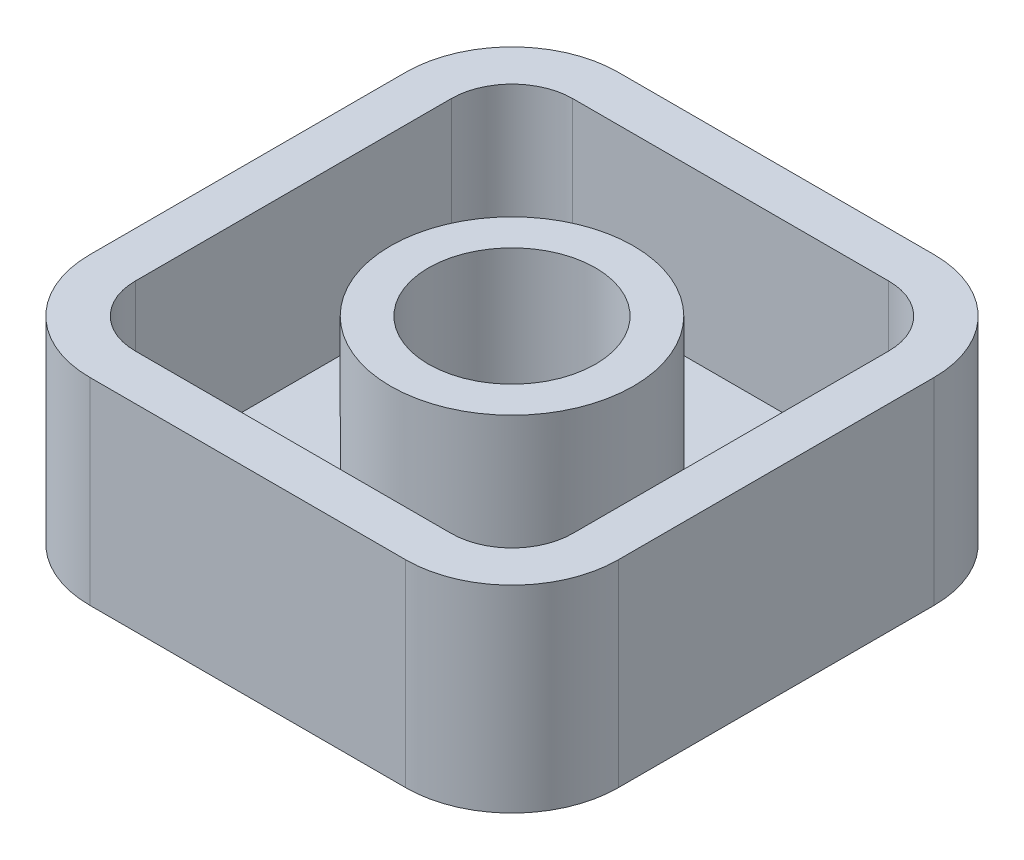
from build123d import *

# Parameters (mm, degrees)
SKETCH1_W           = 17.4
SKETCH1_H           = 17.4
BOSS_EXTRUDE1_DEPTH = 6.5
FILLET1_R           = 3.5
CUT_EXTRUDE1_DEPTH  = 5.5
SKETCH3_R           = 4
SKETCH3_R_2         = 2.75
BOSS_EXTRUDE2_DEPTH = 5.5
SKETCH4_R           = 2.75
CUT_EXTRUDE2_DEPTH  = 0.4


with BuildPart() as part:
    # Sketch1 → Boss-Extrude1 (new body)
    with BuildSketch(Plane(origin=(0, 0, 0), x_dir=(1, 0, 0), z_dir=(0, 1, 0))):
        with Locations((-8.7, -8.7)):
            Rectangle(SKETCH1_W, SKETCH1_H)
    extrude(amount=BOSS_EXTRUDE1_DEPTH)

    # Fillet1
    fillet1_edges = [part.edges().sort_by_distance(p)[0] for p in [
        (0, 3.25, 17.4),
        (-17.4, 3.25, 17.4),
        (-17.4, 3.25, 0),
        (0, 3.25, 0),
    ]]
    fillet(fillet1_edges, radius=FILLET1_R)

    # Sketch2 → Cut-Extrude1 (cut)
    with BuildSketch(Plane(origin=(0, 6.5, 0), x_dir=(1, 0, 0), z_dir=(0, 1, 0))):
        with BuildLine():
            Line((-13.9, -15.9), (-3.5, -15.9))
            ThreePointArc((-3.5, -15.9), (-2.085786438, -15.314213562), (-1.5, -13.9))
            Line((-1.5, -13.9), (-1.5, -3.5))
            ThreePointArc((-1.5, -3.5), (-2.085786438, -2.085786438), (-3.5, -1.5))
            Line((-3.5, -1.5), (-13.9, -1.5))
            ThreePointArc((-13.9, -1.5), (-15.314213562, -2.085786438), (-15.9, -3.5))
            Line((-15.9, -3.5), (-15.9, -13.9))
            ThreePointArc((-15.9, -13.9), (-15.314213562, -15.314213562), (-13.9, -15.9))
        make_face()
    extrude(amount=-CUT_EXTRUDE1_DEPTH, mode=Mode.SUBTRACT)

    # Sketch3 → Boss-Extrude2 (add)
    with BuildSketch(Plane(origin=(0, 1, 0), x_dir=(1, 0, 0), z_dir=(0, 1, 0))):
        with Locations((-8.7, -8.7)):
            Circle(SKETCH3_R)
        with Locations((-8.7, -8.7)):
            Circle(SKETCH3_R_2, mode=Mode.SUBTRACT)
    extrude(amount=BOSS_EXTRUDE2_DEPTH)

    # Sketch4 → Cut-Extrude2 (cut)
    with BuildSketch(Plane(origin=(0, 1, 0), x_dir=(1, 0, 0), z_dir=(0, 1, 0))):
        with Locations((-8.7, -8.7)):
            Circle(SKETCH4_R)
    extrude(amount=-CUT_EXTRUDE2_DEPTH, mode=Mode.SUBTRACT)


solid = part.part
